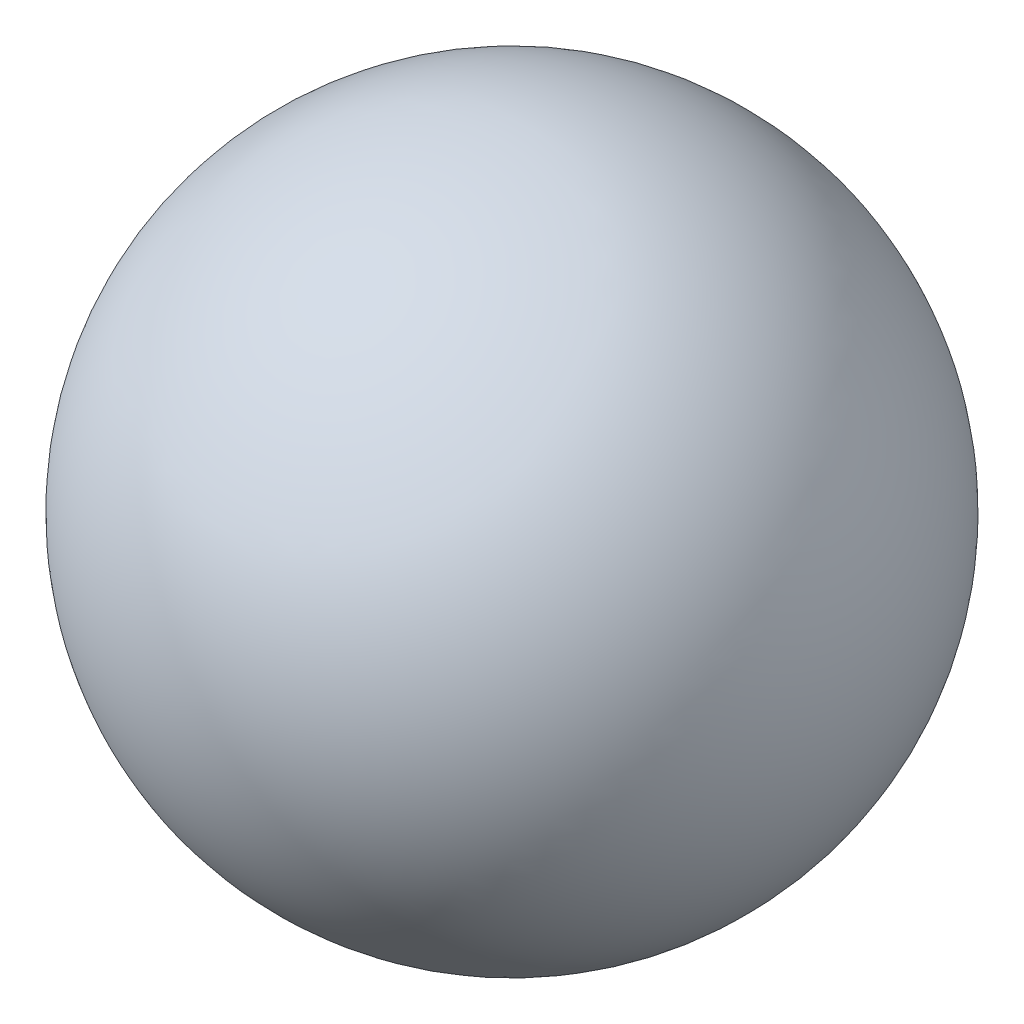
from build123d import *


with BuildPart() as part:
    # Sketch1 → Revolve3 (revolve)
    with BuildSketch(Plane(origin=(0, 0, 0), x_dir=(1, 0, 0), z_dir=(0, 1, 0))):
        with BuildLine():
            Line((0, 6.35), (0, -6.35))
            ThreePointArc((0, -6.35), (-6.35, 0), (0, 6.35))
        make_face()
    revolve(axis=Axis((0, 0, -6.35), (0, 0, 1)))


solid = part.part
